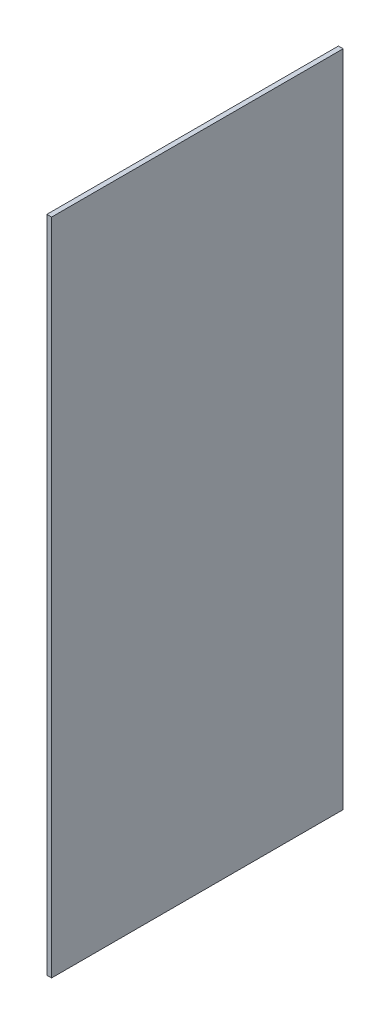
from build123d import *

# Parameters (mm, degrees)
SKETCH2_W           = 100
SKETCH2_H           = 226
BOSS_EXTRUDE1_DEPTH = 1.6256


with BuildPart() as part:
    # Sketch2 → Boss-Extrude1 (new body)
    with BuildSketch(Plane(origin=(0, 0, 0), x_dir=(0, 0, -1), z_dir=(1, 0, 0))):
        Rectangle(SKETCH2_W, SKETCH2_H)
    extrude(amount=BOSS_EXTRUDE1_DEPTH)


solid = part.part
